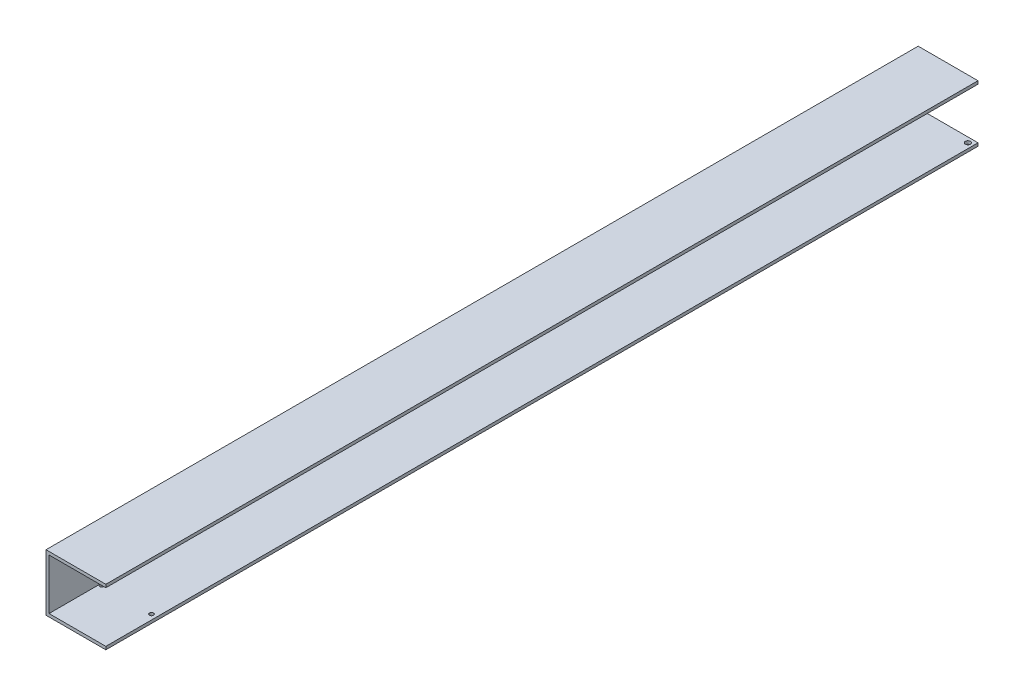
from build123d import *

# Parameters (mm, degrees)
ESTRUSIONE_ESTRUSIONE1_DEPTH = 1005
SCHIZZO2_R                   = 2
TAGLIO_ESTRUSIONE1_DEPTH     = 50
SCHIZZO3_R                   = 2.5
TAGLIO_ESTRUSIONE2_DEPTH     = 50
SCHIZZO4_W                   = 59
SCHIZZO4_H                   = 145
TAGLIO_ESTRUSIONE3_DEPTH     = 63
SCHIZZO8_R                   = 2.5
TAGLIO_ESTRUSIONE5_DEPTH     = 10


with BuildPart() as part:
    # Schizzo1 → Estrusione-Estrusione1 (new body)
    with BuildSketch(Plane.XY):
        Polygon((28, -25), (28, -28), (-31, -28), (-31, 28), (28, 28), (28, 25), (-28, 25), (-28, -25), align=None)
    extrude(amount=ESTRUSIONE_ESTRUSIONE1_DEPTH)

    # Schizzo2 → Taglio-Estrusione1 (cut)
    with BuildSketch(Plane(origin=(0, -28, 0), x_dir=(-1, 0, 0), z_dir=(0, -1, 0))):
        with Locations((-23, -955)):
            Circle(SCHIZZO2_R)
        with Locations((26, -955)):
            Circle(SCHIZZO2_R)
    extrude(amount=-TAGLIO_ESTRUSIONE1_DEPTH, mode=Mode.SUBTRACT)

    # Schizzo3 → Taglio-Estrusione2 (cut)
    with BuildSketch(Plane(origin=(0, -28, 0), x_dir=(-1, 0, 0), z_dir=(0, -1, 0))):
        with Locations((26, -150)):
            Circle(SCHIZZO3_R)
        with Locations((-23, -150)):
            Circle(SCHIZZO3_R)
    extrude(amount=-TAGLIO_ESTRUSIONE2_DEPTH, mode=Mode.SUBTRACT)

    # Schizzo4 → Taglio-Estrusione3 (cut)
    with BuildSketch(Plane(origin=(0, 28, 0), x_dir=(1, 0, 0), z_dir=(0, 1, 0))):
        with Locations((-1.5, -72.5)):
            Rectangle(SCHIZZO4_W, SCHIZZO4_H)
    extrude(amount=-TAGLIO_ESTRUSIONE3_DEPTH, mode=Mode.SUBTRACT)

    # Schizzo8 → Taglio-Estrusione5 (cut)
    with BuildSketch(Plane.ZY.offset(31)):
        with Locations((175, -7)):
            Circle(SCHIZZO8_R)
        with Locations((225, -7)):
            Circle(SCHIZZO8_R)
    extrude(amount=-TAGLIO_ESTRUSIONE5_DEPTH, mode=Mode.SUBTRACT)


solid = part.part
